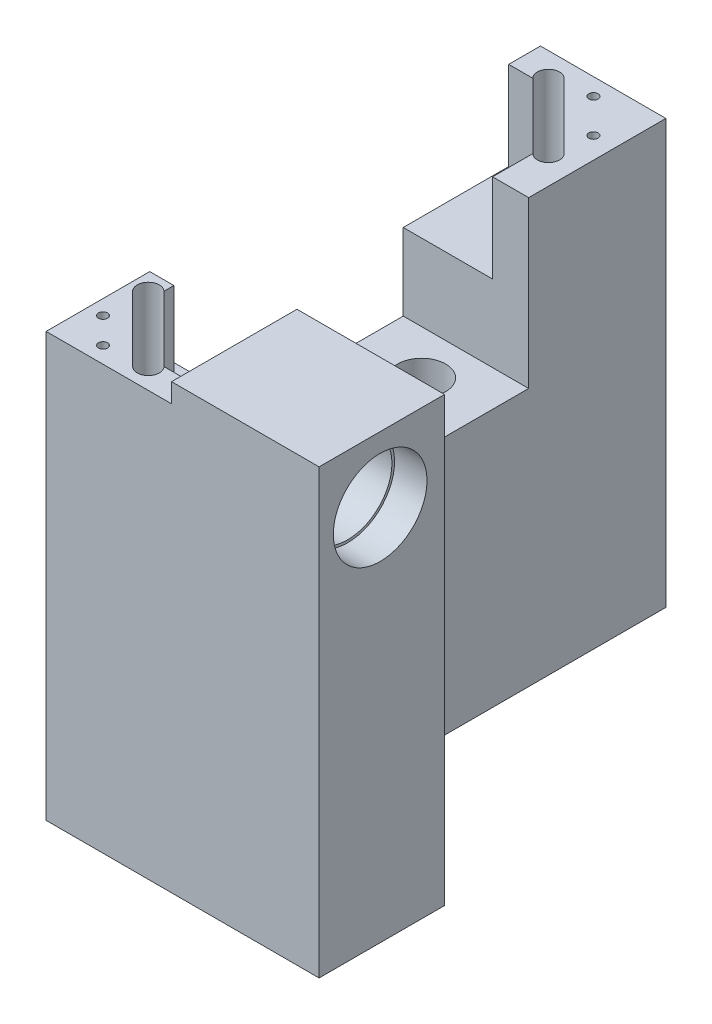
from build123d import *

# Parameters (mm, degrees)
BOSS_EXTRUDE1_DEPTH            = 45
SKETCH2_W                      = 17
SKETCH2_H                      = 31.401973819
CUT_EXTRUDE1_DEPTH             = 25
BOSS_EXTRUDE2_DEPTH            = 15
SKETCH5_W                      = 17
SKETCH5_H                      = 18.598026181
CUT_EXTRUDE2_DEPTH             = 2.6
CUT_EXTRUDE3_DEPTH             = 12
CUT_EXTRUDE4_DEPTH             = 14.6
SKETCH4_R                      = 6.35
CUT_EXTRUDE6_DEPTH             = 4.4
SKETCH11_R                     = 6
CUT_EXTRUDE7_DEPTH             = 5
SM05_TAPPED_HOLE1_D            = 12.7
SM05_TAPPED_HOLE1_DEPTH        = 3
SM05_TAPPED_HOLE1_TIP          = 3.815464931
CUT_EXTRUDE9_DEPTH             = 12.5
CUT_EXTRUDE10_DEPTH            = 0.5
CUT_EXTRUDE11_DEPTH            = 2.6
SKETCH18_R                     = 4.89982915
CUT_EXTRUDE12_DEPTH            = 10.6
CBORE_FOR_M3_SHCS1_D           = 3.4
CBORE_FOR_M3_SHCS1_DEPTH       = 35
CBORE_FOR_M3_SHCS1_CBORE_D     = 6.5
CBORE_FOR_M3_SHCS1_CBORE_DEPTH = 25
F_3_0MM_DOWEL_HOLE1_D          = 3
F_3_0MM_DOWEL_HOLE1_DEPTH      = 5.2
F_3_0MM_DOWEL_HOLE1_TIP        = 0.901290929
M1_6_TAPPED_HOLE1_D            = 1.25
M1_6_TAPPED_HOLE1_DEPTH        = 4.25
M1_6_TAPPED_HOLE1_TIP          = 0.375537887
M1_6_TAPPED_HOLE2_D            = 1.25
M1_6_TAPPED_HOLE2_DEPTH        = 4.25
M1_6_TAPPED_HOLE2_TIP          = 0.375537887


with BuildPart() as part:
    # Sketch1 → Boss-Extrude1 (new body)
    with BuildSketch(Plane(origin=(0, 0, 0), x_dir=(1, 0, 0), z_dir=(0, 1, 0))):
        Polygon((27.364828995, -34.317342946), (-9.635171005, -34.317342946), (-9.635171005, 32.682657054), (7.364828995, 32.682657054), (7.364828995, -17.317342946), (27.364828995, -17.317342946), align=None)
    extrude(amount=BOSS_EXTRUDE1_DEPTH)

    # Sketch2 → Cut-Extrude1 (cut)
    with BuildSketch(Plane(origin=(0, 45, 0), x_dir=(1, 0, 0), z_dir=(0, 1, 0))):
        with Locations((-1.135171005, -1.616356037)):
            Rectangle(SKETCH2_W, SKETCH2_H)
    extrude(amount=-CUT_EXTRUDE1_DEPTH, mode=Mode.SUBTRACT)

    # Sketch3 → Boss-Extrude2 (add)
    with BuildSketch(Plane.XZ):
        Polygon((27.364828995, 34.317342946), (-9.635171005, 34.317342946), (-9.635171005, -32.682657054), (7.364828995, -32.682657054), (7.364828995, 17.317342946), (27.364828995, 17.317342946), align=None)
    extrude(amount=BOSS_EXTRUDE2_DEPTH)

    # Sketch5 → Cut-Extrude2 (cut)
    with BuildSketch(Plane(origin=(0, 45, 0), x_dir=(1, 0, 0), z_dir=(0, 1, 0))):
        with Locations((-1.135171005, 23.383643964)):
            Rectangle(SKETCH5_W, SKETCH5_H)
    extrude(amount=-CUT_EXTRUDE2_DEPTH, mode=Mode.SUBTRACT)

    # Sketch6 → Cut-Extrude3 (cut)
    with BuildSketch(Plane(origin=(0, 42.4, 0), x_dir=(1, 0, 0), z_dir=(0, 1, 0))):
        Polygon((-9.635171005, 28.375993351), (-9.635171005, 14.084630873), (2.47645738, 14.084630873), (2.47645738, 19.537158586), (-6.362377384, 28.375993351), align=None)
    extrude(amount=-CUT_EXTRUDE3_DEPTH, mode=Mode.SUBTRACT)

    # Sketch7 → Cut-Extrude4 (cut)
    with BuildSketch(Plane(origin=(0, 45, 0), x_dir=(1, 0, 0), z_dir=(0, 1, 0))):
        with BuildLine():
            Line((2.47645738, -30.462841414), (7.364828995, -30.462841414))
            Line((7.364828995, -30.462841414), (7.364828995, -17.317342946))
            Line((7.364828995, -17.317342946), (-9.635171005, -17.317342946))
            Line((-9.635171005, -17.317342946), (-9.635171005, -20.274833742))
            Line((-9.635171005, -20.274833742), (-6.362377384, -20.274833742))
            Line((-6.362377384, -20.274833742), (-6.362377384, -21.624006649))
            ThreePointArc((-6.362377384, -21.624006649), (-8.483697728, -21.624006649), (-8.483697728, -23.745326993))
            Line((-8.483697728, -23.745326993), (0.355137037, -32.584161758))
            ThreePointArc((0.355137037, -32.584161758), (2.47645738, -32.584161758), (2.47645738, -30.462841414))
        make_face()
    extrude(amount=-CUT_EXTRUDE4_DEPTH, mode=Mode.SUBTRACT)

    # Sketch4 → Cut-Extrude6 (cut)
    with BuildSketch(Plane(origin=(27.364828995, 0, 0), x_dir=(0, 0, -1), z_dir=(1, 0, 0))):
        with Locations((-26.043424032, 36.1)):
            Circle(SKETCH4_R)
    extrude(amount=-CUT_EXTRUDE6_DEPTH, mode=Mode.SUBTRACT)

    # Sketch11 → Cut-Extrude7 (cut)
    with BuildSketch(Plane(origin=(22.964828995, 0, 0), x_dir=(0, 0, -1), z_dir=(1, 0, 0))):
        with Locations((-26.043424032, 36.1)):
            Circle(SKETCH11_R)
    extrude(amount=-CUT_EXTRUDE7_DEPTH, mode=Mode.SUBTRACT)

    # SM05 Tapped Hole1
    with Locations(Plane(origin=(27.364828995, 0, 0), x_dir=(0, 0, -1), z_dir=(1, 0, 0))):
        with Locations((-26.043424032, 36.1)):
            Hole(SM05_TAPPED_HOLE1_D / 2, depth=SM05_TAPPED_HOLE1_DEPTH)
            with Locations((0, 0, -(SM05_TAPPED_HOLE1_DEPTH + SM05_TAPPED_HOLE1_TIP / 2))):  # 118° drill point
                Cone(0, SM05_TAPPED_HOLE1_D / 2, SM05_TAPPED_HOLE1_TIP, mode=Mode.SUBTRACT)

    # Sketch15 → Cut-Extrude9 (cut)
    with BuildSketch(Plane(origin=(0, 42.4, 0), x_dir=(1, 0, 0), z_dir=(0, 1, 0))):
        with BuildLine():
            Line((-4.241057041, 30.497313694), (4.597777724, 21.658478929))
            ThreePointArc((4.597777724, 21.658478929), (4.597777724, 19.537158586), (2.47645738, 19.537158586))
            Line((2.47645738, 19.537158586), (-6.362377384, 28.375993351))
            ThreePointArc((-6.362377384, 28.375993351), (-6.362377384, 30.497313694), (-4.241057041, 30.497313694))
        make_face()
    extrude(amount=-CUT_EXTRUDE9_DEPTH, mode=Mode.SUBTRACT)

    # Sketch16 → Cut-Extrude10 (cut)
    with BuildSketch(Plane(origin=(0, 30.4, 0), x_dir=(1, 0, 0), z_dir=(0, 1, 0))):
        with BuildLine():
            Line((-6.362377384, -21.624006649), (2.47645738, -30.462841414))
            ThreePointArc((2.47645738, -30.462841414), (2.47645738, -32.584161758), (0.355137037, -32.584161758))
            Line((0.355137037, -32.584161758), (-8.483697728, -23.745326993))
            ThreePointArc((-8.483697728, -23.745326993), (-8.483697728, -21.624006649), (-6.362377384, -21.624006649))
        make_face()
    extrude(amount=-CUT_EXTRUDE10_DEPTH, mode=Mode.SUBTRACT)

    # Sketch17 → Cut-Extrude11 (cut)
    with BuildSketch(Plane(origin=(0, 45, 0), x_dir=(1, 0, 0), z_dir=(0, 1, 0))):
        with BuildLine():
            Line((7.364828995, -30.462841414), (7.364828995, -34.317342946))
            Line((7.364828995, -34.317342946), (-9.635171005, -34.317342946))
            Line((-9.635171005, -34.317342946), (-9.635171005, -20.274833742))
            Line((-9.635171005, -20.274833742), (-6.362377384, -20.274833742))
            Line((-6.362377384, -20.274833742), (-6.362377384, -21.624006649))
            ThreePointArc((-6.362377384, -21.624006649), (-8.483697728, -21.624006649), (-8.483697728, -23.745326993))
            Line((-8.483697728, -23.745326993), (0.355137037, -32.584161758))
            ThreePointArc((0.355137037, -32.584161758), (2.47645738, -32.584161758), (2.47645738, -30.462841414))
            Line((2.47645738, -30.462841414), (7.364828995, -30.462841414))
        make_face()
    extrude(amount=-CUT_EXTRUDE11_DEPTH, mode=Mode.SUBTRACT)

    # Sketch18 → Cut-Extrude12 (cut)
    with BuildSketch(Plane(origin=(17.964828995, 0, 0), x_dir=(0, 0, -1), z_dir=(1, 0, 0))):
        with Locations((-26.043424032, 36.1)):
            Circle(SKETCH18_R)
    extrude(amount=-CUT_EXTRUDE12_DEPTH, mode=Mode.SUBTRACT)

    # CBORE for M3 SHCS1
    with Locations(Plane(origin=(0, 20, 0), x_dir=(1, 0, 0), z_dir=(0, 1, 0))):
        with Locations((-1.135171005, 8.084630873), (-1.135171005, -11.317342946)):
            CounterBoreHole(CBORE_FOR_M3_SHCS1_D / 2, CBORE_FOR_M3_SHCS1_CBORE_D / 2, CBORE_FOR_M3_SHCS1_CBORE_DEPTH, depth=CBORE_FOR_M3_SHCS1_DEPTH)

    # Ø3.0mm Dowel Hole1
    with Locations(Plane(origin=(0, -15, 0), x_dir=(-1, 0, 0), z_dir=(0, -1, 0))):
        with Locations((-19.364828995, -26.317342946), (1.135171005, 24.682657054)):
            Hole(F_3_0MM_DOWEL_HOLE1_D / 2, depth=F_3_0MM_DOWEL_HOLE1_DEPTH)
            with Locations((0, 0, -(F_3_0MM_DOWEL_HOLE1_DEPTH + F_3_0MM_DOWEL_HOLE1_TIP / 2))):  # 118° drill point
                Cone(0, F_3_0MM_DOWEL_HOLE1_D / 2, F_3_0MM_DOWEL_HOLE1_TIP, mode=Mode.SUBTRACT)

    # M1.6 Tapped Hole1
    with Locations(Plane(origin=(0, 42.4, 0), x_dir=(1, 0, 0), z_dir=(0, 1, 0))):
        with Locations((-0.132659145, 30.363070903), (4.463534932, 25.766876825)):
            Hole(M1_6_TAPPED_HOLE1_D / 2, depth=M1_6_TAPPED_HOLE1_DEPTH)
            with Locations((0, 0, -(M1_6_TAPPED_HOLE1_DEPTH + M1_6_TAPPED_HOLE1_TIP / 2))):  # 118° drill point
                Cone(0, M1_6_TAPPED_HOLE1_D / 2, M1_6_TAPPED_HOLE1_TIP, mode=Mode.SUBTRACT)

    # M1.6 Tapped Hole2
    with Locations(Plane(origin=(0, 42.4, 0), x_dir=(1, 0, 0), z_dir=(0, 1, 0))):
        with Locations((-4.135171005, -32.107144182), (-7.635171005, -28.607144182)):
            Hole(M1_6_TAPPED_HOLE2_D / 2, depth=M1_6_TAPPED_HOLE2_DEPTH)
            with Locations((0, 0, -(M1_6_TAPPED_HOLE2_DEPTH + M1_6_TAPPED_HOLE2_TIP / 2))):  # 118° drill point
                Cone(0, M1_6_TAPPED_HOLE2_D / 2, M1_6_TAPPED_HOLE2_TIP, mode=Mode.SUBTRACT)


solid = part.part
